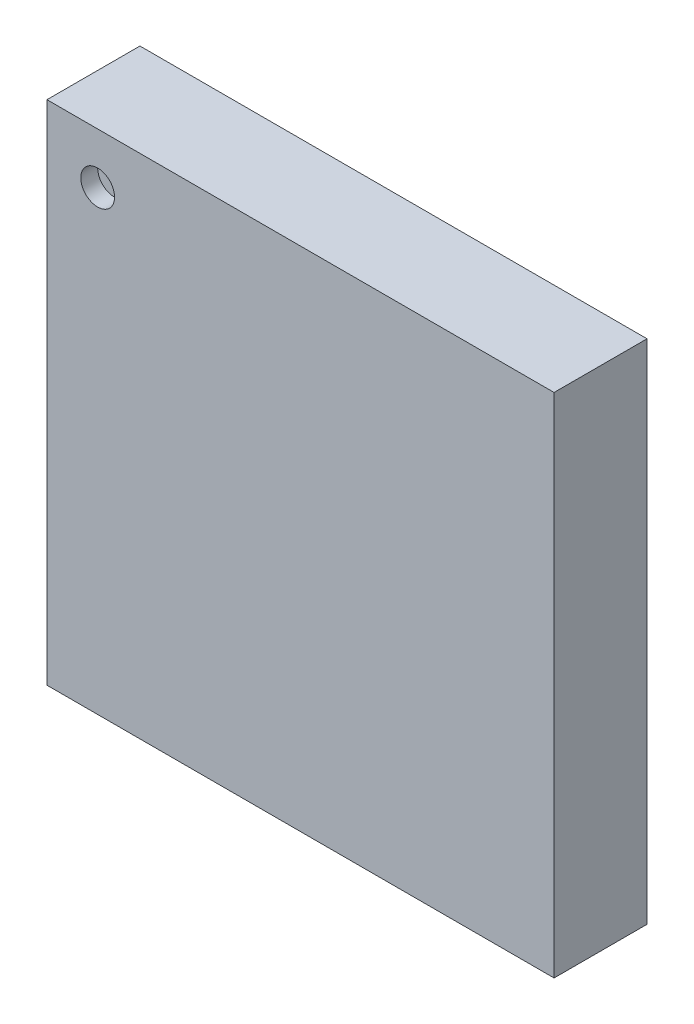
from build123d import *

# Parameters (mm, degrees)
SKETCH1_W           = 3
SKETCH1_H           = 3
BOSS_EXTRUDE1_DEPTH = 0.55
SKETCH2_R           = 0.1
CUT_EXTRUDE1_DEPTH  = 0.1
SKETCH3_W           = 0.32
SKETCH3_H           = 0.32
BOSS_EXTRUDE2_DEPTH = 0.02


with BuildPart() as part:
    # Sketch1 → Boss-Extrude1 (new body)
    with BuildSketch(Plane.XY):
        with Locations((1.5, 1.5)):
            Rectangle(SKETCH1_W, SKETCH1_H)
    extrude(amount=BOSS_EXTRUDE1_DEPTH)

    # Sketch2 → Cut-Extrude1 (cut)
    with BuildSketch(Plane.XY.offset(0.55)):
        with Locations((0.3, 2.7)):
            Circle(SKETCH2_R)
    extrude(amount=-CUT_EXTRUDE1_DEPTH, mode=Mode.SUBTRACT)

    # Sketch3 → Boss-Extrude2 (add)
    with BuildSketch(Plane(origin=(0, 0, 0), x_dir=(-1, 0, 0), z_dir=(0, 0, -1))):
        with Locations((-2.765, 2.765)):
            Rectangle(SKETCH3_W, SKETCH3_H)
        with Locations((-0.235, 2.765)):
            Rectangle(SKETCH3_W, SKETCH3_H)
        with Locations((-0.235, 0.235)):
            Rectangle(SKETCH3_W, SKETCH3_H)
        with Locations((-2.765, 0.235)):
            Rectangle(SKETCH3_W, SKETCH3_H)
        Polygon((-0.85, 2.35), (-0.65, 2.15), (-0.65, 0.65), (-2.35, 0.65), (-2.35, 2.35), align=None)
        with BuildLine():
            Line((-2.375, 2.9), (-2.125, 2.9))
            Line((-2.125, 2.9), (-2.125, 2.617575378))
            ThreePointArc((-2.125, 2.617575378), (-2.25, 2.5), (-2.375, 2.617575378))
            Line((-2.375, 2.617575378), (-2.375, 2.9))
        make_face()
        with BuildLine():
            Line((-1.875, 2.9), (-1.625, 2.9))
            Line((-1.625, 2.9), (-1.625, 2.617575378))
            ThreePointArc((-1.625, 2.617575378), (-1.75, 2.5), (-1.875, 2.617575378))
            Line((-1.875, 2.617575378), (-1.875, 2.9))
        make_face()
        with BuildLine():
            Line((-1.375, 2.9), (-1.125, 2.9))
            Line((-1.125, 2.9), (-1.125, 2.617575378))
            ThreePointArc((-1.125, 2.617575378), (-1.25, 2.5), (-1.375, 2.617575378))
            Line((-1.375, 2.617575378), (-1.375, 2.9))
        make_face()
        with BuildLine():
            Line((-0.875, 2.9), (-0.625, 2.9))
            Line((-0.625, 2.9), (-0.625, 2.617575378))
            ThreePointArc((-0.625, 2.617575378), (-0.75, 2.5), (-0.875, 2.617575378))
            Line((-0.875, 2.617575378), (-0.875, 2.9))
        make_face()
        with BuildLine():
            Line((-0.1, 2.375), (-0.1, 2.125))
            Line((-0.1, 2.125), (-0.382424622, 2.125))
            ThreePointArc((-0.382424622, 2.125), (-0.5, 2.25), (-0.382424622, 2.375))
            Line((-0.382424622, 2.375), (-0.1, 2.375))
        make_face()
        with BuildLine():
            Line((-0.1, 1.875), (-0.1, 1.625))
            Line((-0.1, 1.625), (-0.382424622, 1.625))
            ThreePointArc((-0.382424622, 1.625), (-0.5, 1.75), (-0.382424622, 1.875))
            Line((-0.382424622, 1.875), (-0.1, 1.875))
        make_face()
        with BuildLine():
            Line((-0.1, 1.375), (-0.1, 1.125))
            Line((-0.1, 1.125), (-0.382424622, 1.125))
            ThreePointArc((-0.382424622, 1.125), (-0.5, 1.25), (-0.382424622, 1.375))
            Line((-0.382424622, 1.375), (-0.1, 1.375))
        make_face()
        with BuildLine():
            Line((-0.1, 0.875), (-0.1, 0.625))
            Line((-0.1, 0.625), (-0.382424622, 0.625))
            ThreePointArc((-0.382424622, 0.625), (-0.5, 0.75), (-0.382424622, 0.875))
            Line((-0.382424622, 0.875), (-0.1, 0.875))
        make_face()
        with BuildLine():
            Line((-0.625, 0.1), (-0.875, 0.1))
            Line((-0.875, 0.1), (-0.875, 0.382424622))
            ThreePointArc((-0.875, 0.382424622), (-0.75, 0.5), (-0.625, 0.382424622))
            Line((-0.625, 0.382424622), (-0.625, 0.1))
        make_face()
        with BuildLine():
            Line((-1.125, 0.1), (-1.375, 0.1))
            Line((-1.375, 0.1), (-1.375, 0.382424622))
            ThreePointArc((-1.375, 0.382424622), (-1.25, 0.5), (-1.125, 0.382424622))
            Line((-1.125, 0.382424622), (-1.125, 0.1))
        make_face()
        with BuildLine():
            Line((-1.625, 0.1), (-1.875, 0.1))
            Line((-1.875, 0.1), (-1.875, 0.382424622))
            ThreePointArc((-1.875, 0.382424622), (-1.75, 0.5), (-1.625, 0.382424622))
            Line((-1.625, 0.382424622), (-1.625, 0.1))
        make_face()
        with BuildLine():
            Line((-2.125, 0.1), (-2.375, 0.1))
            Line((-2.375, 0.1), (-2.375, 0.382424622))
            ThreePointArc((-2.375, 0.382424622), (-2.25, 0.5), (-2.125, 0.382424622))
            Line((-2.125, 0.382424622), (-2.125, 0.1))
        make_face()
        with BuildLine():
            Line((-2.9, 0.625), (-2.9, 0.875))
            Line((-2.9, 0.875), (-2.617575378, 0.875))
            ThreePointArc((-2.617575378, 0.875), (-2.5, 0.75), (-2.617575378, 0.625))
            Line((-2.617575378, 0.625), (-2.9, 0.625))
        make_face()
        with BuildLine():
            Line((-2.9, 1.125), (-2.9, 1.375))
            Line((-2.9, 1.375), (-2.617575378, 1.375))
            ThreePointArc((-2.617575378, 1.375), (-2.5, 1.25), (-2.617575378, 1.125))
            Line((-2.617575378, 1.125), (-2.9, 1.125))
        make_face()
        with BuildLine():
            Line((-2.9, 1.625), (-2.9, 1.875))
            Line((-2.9, 1.875), (-2.617575378, 1.875))
            ThreePointArc((-2.617575378, 1.875), (-2.5, 1.75), (-2.617575378, 1.625))
            Line((-2.617575378, 1.625), (-2.9, 1.625))
        make_face()
        with BuildLine():
            Line((-2.9, 2.125), (-2.9, 2.375))
            Line((-2.9, 2.375), (-2.617575378, 2.375))
            ThreePointArc((-2.617575378, 2.375), (-2.5, 2.25), (-2.617575378, 2.125))
            Line((-2.617575378, 2.125), (-2.9, 2.125))
        make_face()
    extrude(amount=BOSS_EXTRUDE2_DEPTH)


solid = part.part
